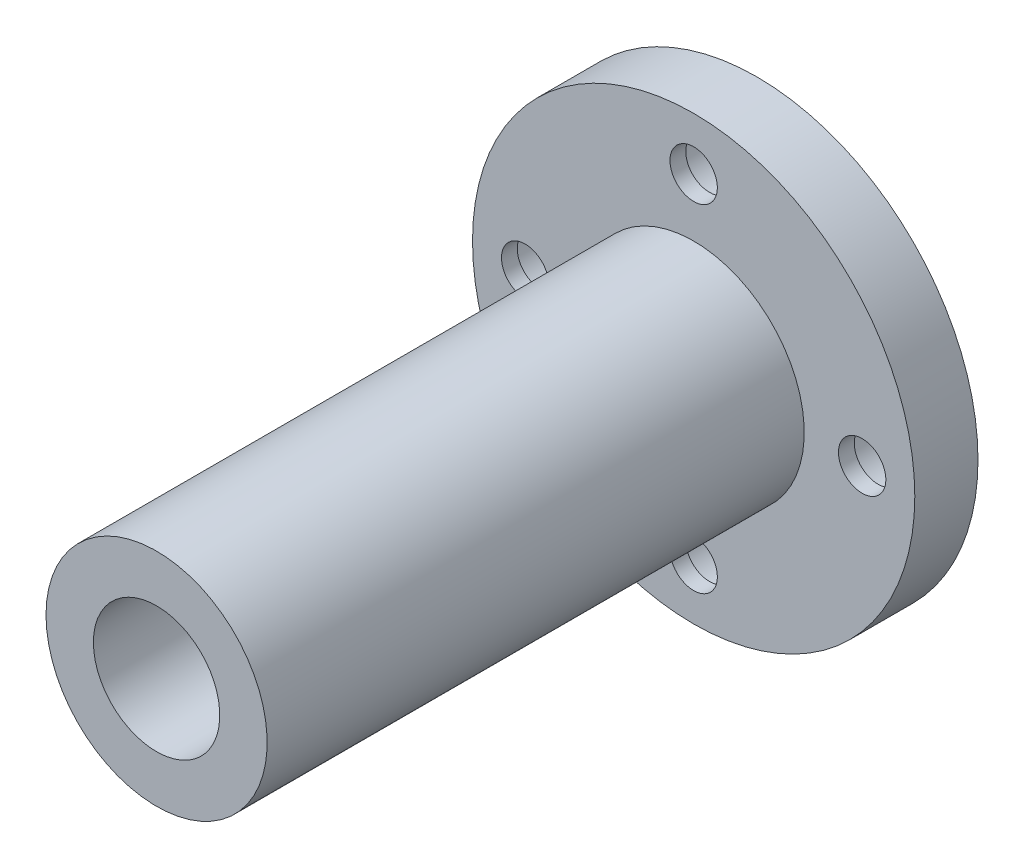
from build123d import *

# Parameters (mm, degrees)
CROQUIS6_R            = 2.25
CORTAR_EXTRUIR3_DEPTH = 7
CROQUIS7_R            = 3.75
CORTAR_EXTRUIR4_DEPTH = 4.5


with BuildPart() as part:
    # Croquis5 → Revolución1 (revolve)
    with BuildSketch(Plane(origin=(0, 0, 0), x_dir=(0, 0, -1), z_dir=(1, 0, 0))):
        Polygon((0, 6), (-57, 6), (-57, 10.5), (-6, 10.5), (-6, 21), (0, 21), align=None)
    revolve(axis=Axis((0, 0, 0), (0, 0, 1)))

    # Croquis6 → Cortar-Extruir3 (cut, through all)
    with BuildSketch(Plane.XY.offset(6)):
        with Locations((0, 16)):
            Circle(CROQUIS6_R)
        with Locations((16, 0)):
            Circle(CROQUIS6_R)
        with Locations((0, -16)):
            Circle(CROQUIS6_R)
        with Locations((-16, 0)):
            Circle(CROQUIS6_R)
    extrude(amount=-CORTAR_EXTRUIR3_DEPTH, mode=Mode.SUBTRACT)

    # Croquis7 → Cortar-Extruir4 (cut)
    with BuildSketch(Plane(origin=(0, 0, 0), x_dir=(-1, 0, 0), z_dir=(0, 0, -1))):
        with Locations((0, 16)):
            Circle(CROQUIS7_R)
        with Locations((16, 0)):
            Circle(CROQUIS7_R)
        with Locations((0, -16)):
            Circle(CROQUIS7_R)
        with Locations((-16, 0)):
            Circle(CROQUIS7_R)
    extrude(amount=-CORTAR_EXTRUIR4_DEPTH, mode=Mode.SUBTRACT)


solid = part.part
